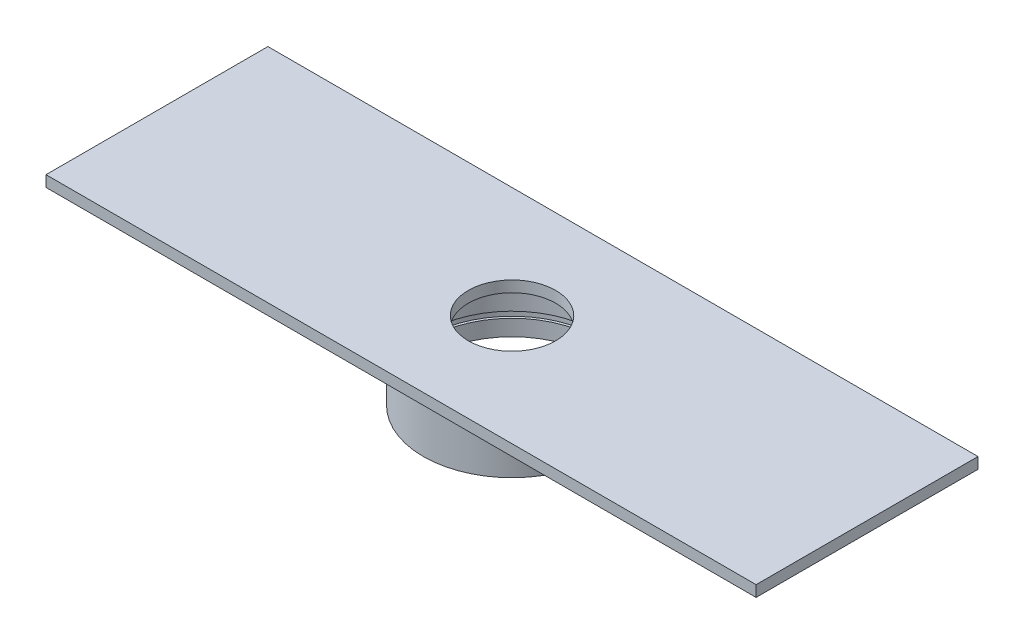
from build123d import *

# Parameters (mm, degrees)
SKETCH1_R           = 25.4
SKETCH1_R_2         = 24
BOSS_EXTRUDE1_DEPTH = 19.05
SKETCH3_R           = 24.7
CUT_EXTRUDE1_DEPTH  = 1.75
SKETCH4_W           = 203.2
SKETCH4_H           = 63.5
SKETCH4_R           = 12.5
BOSS_EXTRUDE2_DEPTH = 3.175


with BuildPart() as part:
    # Sketch1 → Boss-Extrude1 (new body)
    with BuildSketch(Plane(origin=(0, 0, 0), x_dir=(1, 0, 0), z_dir=(0, 1, 0))):
        Circle(SKETCH1_R)
        Circle(SKETCH1_R_2, mode=Mode.SUBTRACT)
    extrude(amount=BOSS_EXTRUDE1_DEPTH)

    # Sketch3 → Cut-Extrude1 (cut)
    with BuildSketch(Plane(origin=(0, 6.35, 0), x_dir=(-1, 0, 0), z_dir=(0, -1, 0))):
        Circle(SKETCH3_R)
    extrude(amount=CUT_EXTRUDE1_DEPTH, mode=Mode.SUBTRACT)

    # Sketch4 → Boss-Extrude2 (add)
    with BuildSketch(Plane(origin=(0, 19.05, 0), x_dir=(1, 0, 0), z_dir=(0, 1, 0))):
        Rectangle(SKETCH4_W, SKETCH4_H)
        Circle(SKETCH4_R, mode=Mode.SUBTRACT)
    extrude(amount=BOSS_EXTRUDE2_DEPTH)


solid = part.part
